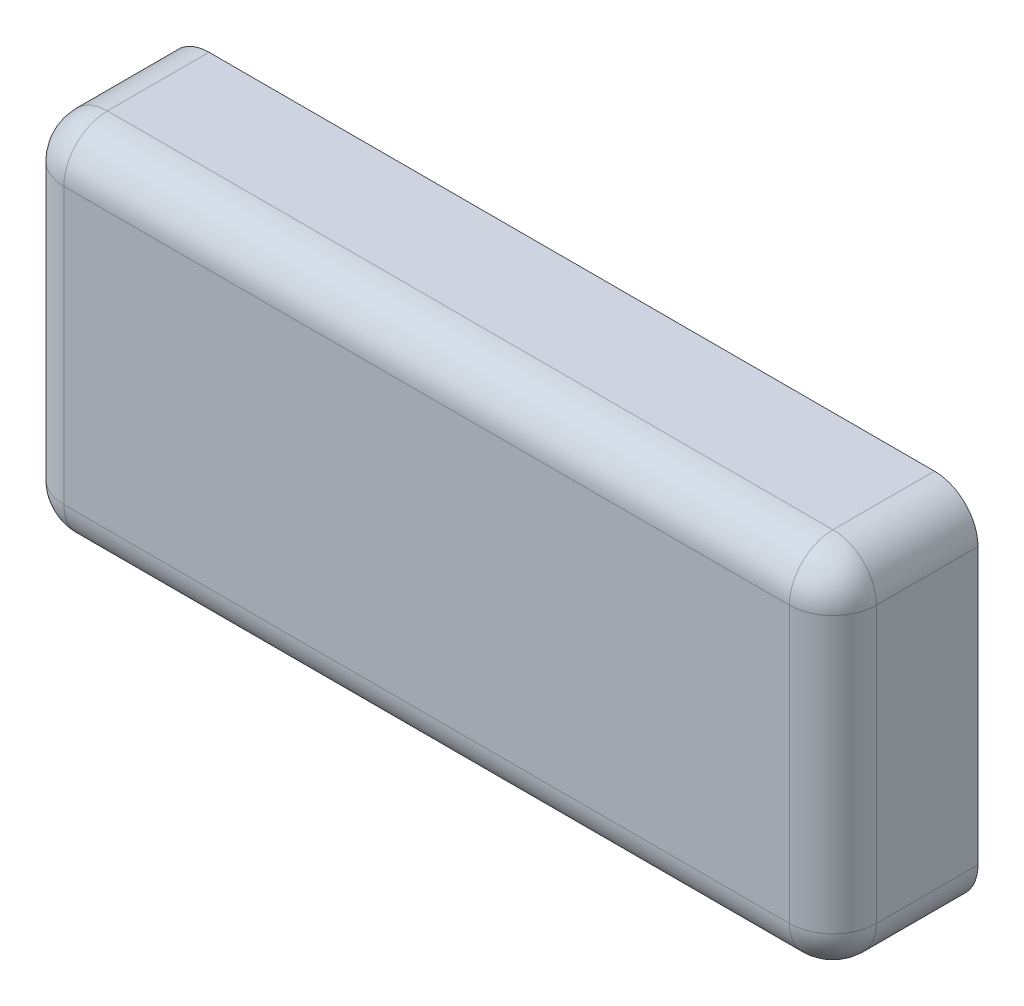
from build123d import *

# Parameters (mm, degrees)
SKETCH1_W      = 14.224
SKETCH1_H      = 6.35
EXTRUDE1_DEPTH = 2.54
FILLET1_R      = 0.762
FILLET2_R      = 0.762


with BuildPart() as part:
    # Sketch1 → Extrude1 (new body)
    with BuildSketch(Plane.XY):
        Rectangle(SKETCH1_W, SKETCH1_H)
    extrude(amount=EXTRUDE1_DEPTH)

    # Fillet1
    fillet1_edges = [part.edges().sort_by_distance(p)[0] for p in [
        (7.112, -3.175, 1.27),
        (-7.112, -3.175, 1.27),
        (-7.112, 3.175, 1.27),
        (7.112, 3.175, 1.27),
    ]]
    fillet(fillet1_edges, radius=FILLET1_R)

    # Fillet2
    fillet2_edges = [part.edges().sort_by_distance(p)[0] for p in [
        (0, -3.175, 2.54),
        (-7.112, 0, 2.54),
        (7.112, 0, 2.54),
        (0, 3.175, 2.54),
        (6.888815367, -2.951815367, 2.54),
        (6.888815367, 2.951815367, 2.54),
        (-6.888815367, 2.951815367, 2.54),
        (-6.888815367, -2.951815367, 2.54),
    ]]
    fillet(fillet2_edges, radius=FILLET2_R)


solid = part.part
